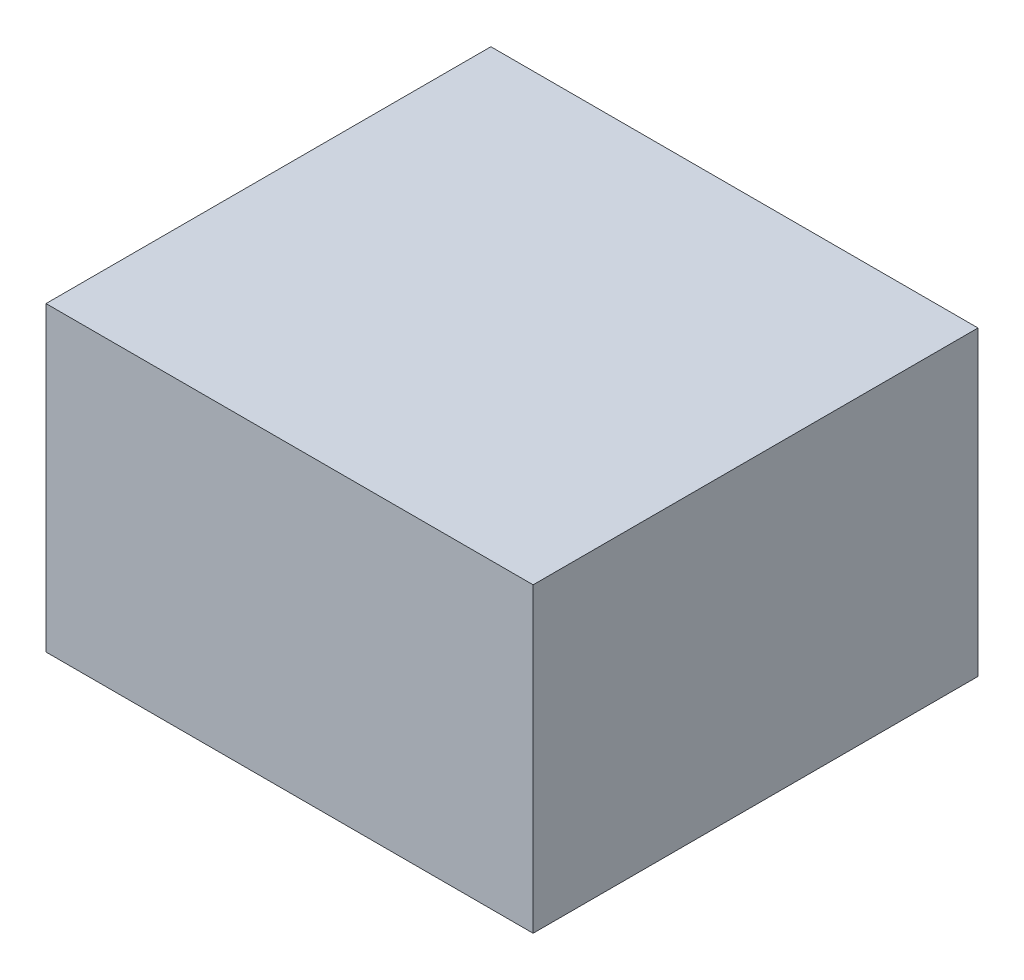
from build123d import *

# Parameters (mm, degrees)
SKETCH1_W           = 87.599012224
SKETCH1_H           = 54.270095116
BOSS_EXTRUDE1_DEPTH = 80


with BuildPart() as part:
    # Sketch1 → Boss-Extrude1 (new body)
    with BuildSketch(Plane.XY):
        Rectangle(SKETCH1_W, SKETCH1_H)
    extrude(amount=BOSS_EXTRUDE1_DEPTH)


solid = part.part
